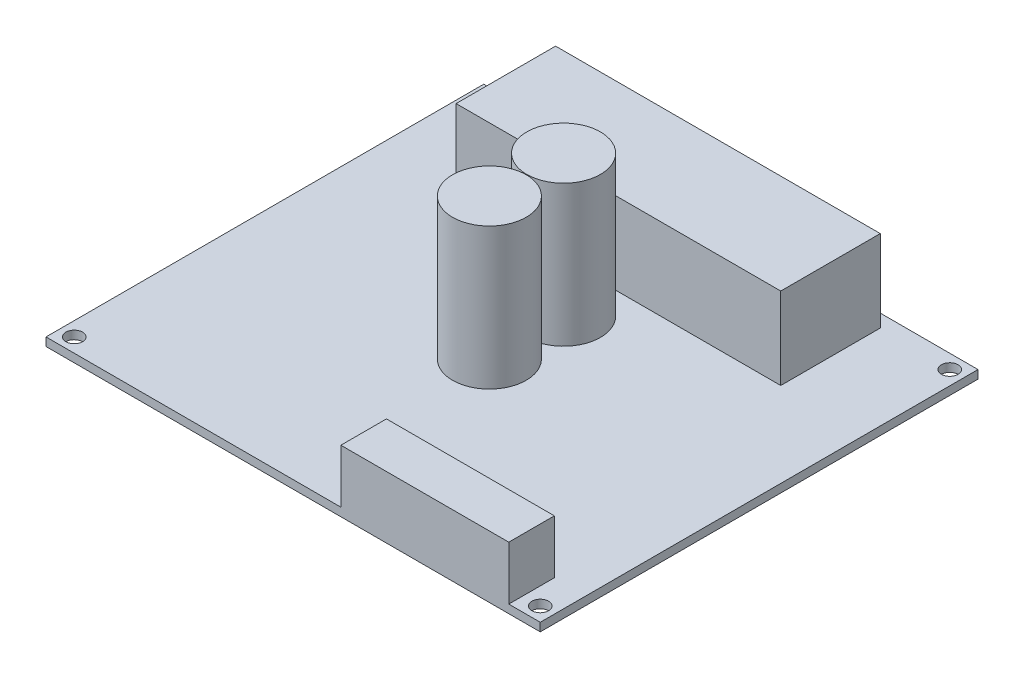
from build123d import *

# Parameters (mm, degrees)
SKETCH1_W           = 88.9
SKETCH1_H           = 78.74
SKETCH1_R           = 1.5
BOSS_EXTRUDE1_DEPTH = 1.5
SKETCH2_W           = 58.4
SKETCH2_H           = 17.9
BOSS_EXTRUDE2_DEPTH = 14.72
SKETCH3_W           = 30.2
SKETCH3_H           = 8.2
BOSS_EXTRUDE3_DEPTH = 9.65
SKETCH4_R           = 6.625
BOSS_EXTRUDE6_DEPTH = 25.4


with BuildPart() as part:
    # Sketch1 → Boss-Extrude1 (new body)
    with BuildSketch(Plane(origin=(0, 0, 0), x_dir=(1, 0, 0), z_dir=(0, 1, 0))):
        Rectangle(SKETCH1_W, SKETCH1_H)
        with Locations((-41.91, 36.83)):
            Circle(SKETCH1_R, mode=Mode.SUBTRACT)
        with Locations((41.91, 36.83)):
            Circle(SKETCH1_R, mode=Mode.SUBTRACT)
        with Locations((41.91, -36.83)):
            Circle(SKETCH1_R, mode=Mode.SUBTRACT)
        with Locations((-41.91, -36.83)):
            Circle(SKETCH1_R, mode=Mode.SUBTRACT)
    extrude(amount=BOSS_EXTRUDE1_DEPTH)

    # Sketch2 → Boss-Extrude2 (add)
    with BuildSketch(Plane(origin=(0, 1.5, 0), x_dir=(1, 0, 0), z_dir=(0, 1, 0))):
        with Locations((0, 28.09)):
            Rectangle(SKETCH2_W, SKETCH2_H)
    extrude(amount=BOSS_EXTRUDE2_DEPTH)

    # Sketch3 → Boss-Extrude3 (add)
    with BuildSketch(Plane(origin=(0, 1.5, 0), x_dir=(1, 0, 0), z_dir=(0, 1, 0))):
        with Locations((23.69, -35.27)):
            Rectangle(SKETCH3_W, SKETCH3_H)
    extrude(amount=BOSS_EXTRUDE3_DEPTH)

    # Sketch4 → Boss-Extrude6 (add)
    with BuildSketch(Plane(origin=(0, 1.5, 0), x_dir=(1, 0, 0), z_dir=(0, 1, 0))):
        with Locations((-1.125, 10.405)):
            Circle(SKETCH4_R)
        with Locations((-1.125, -2.945)):
            Circle(SKETCH4_R)
    extrude(amount=BOSS_EXTRUDE6_DEPTH)


solid = part.part
